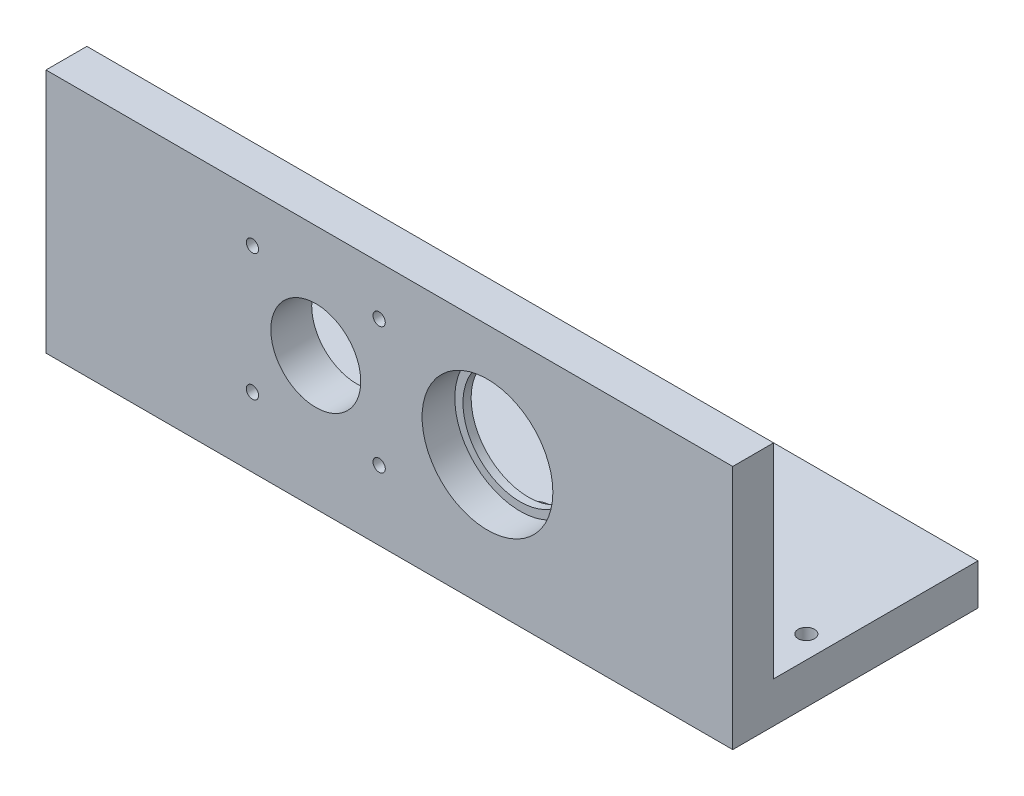
from build123d import *

# Parameters (mm, degrees)
SKIZZE1_W                       = 168
SKIZZE1_H                       = 60
AUFSATZ_LINEAR_AUSTRAGEN1_DEPTH = 10
SKIZZE2_R                       = 14
SCHNITT_LINEAR_AUSTRAGEN1_DEPTH = 27
SKIZZE3_R                       = 16
SCHNITT_LINEAR_AUSTRAGEN2_DEPTH = 8
SKIZZE4_R                       = 11
SCHNITT_LINEAR_AUSTRAGEN3_DEPTH = 21.6
SKIZZE5_W                       = 168
SKIZZE5_H                       = 10
AUFSATZ_LINEAR_AUSTRAGEN2_DEPTH = 50
SKIZZE6_R                       = 2
SCHNITT_LINEAR_AUSTRAGEN4_DEPTH = 10
SKIZZE7_R                       = 2.5
SCHNITT_LINEAR_AUSTRAGEN5_DEPTH = 10
SKIZZE8_R                       = 1.5
SCHNITT_LINEAR_AUSTRAGEN6_DEPTH = 27
FASE1_SIZE                      = 2
FASE2_SIZE                      = 2
FASE3_SIZE                      = 2
FASE4_SIZE                      = 2


with BuildPart() as part:
    # Skizze1 → Aufsatz-Linear austragen1 (new body)
    with BuildSketch(Plane.XY):
        with Locations((84, 30)):
            Rectangle(SKIZZE1_W, SKIZZE1_H)
    extrude(amount=AUFSATZ_LINEAR_AUSTRAGEN1_DEPTH)

    # Skizze2 → Schnitt-Linear austragen1 (cut)
    with BuildSketch(Plane.XY.offset(10)):
        with Locations((108, 32.5)):
            Circle(SKIZZE2_R)
    extrude(amount=-SCHNITT_LINEAR_AUSTRAGEN1_DEPTH, mode=Mode.SUBTRACT)

    # Skizze3 → Schnitt-Linear austragen2 (cut)
    with BuildSketch(Plane.XY.offset(10)):
        with Locations((108, 32.5)):
            Circle(SKIZZE3_R)
    extrude(amount=-SCHNITT_LINEAR_AUSTRAGEN2_DEPTH, mode=Mode.SUBTRACT)

    # Skizze4 → Schnitt-Linear austragen3 (cut)
    with BuildSketch(Plane(origin=(0, 0, 0), x_dir=(-1, 0, 0), z_dir=(0, 0, -1))):
        with Locations((-66, 32.50089026)):
            Circle(SKIZZE4_R)
    extrude(amount=-SCHNITT_LINEAR_AUSTRAGEN3_DEPTH, mode=Mode.SUBTRACT)

    # Skizze5 → Aufsatz-Linear austragen2 (add)
    with BuildSketch(Plane(origin=(0, 0, 0), x_dir=(-1, 0, 0), z_dir=(0, 0, -1))):
        with Locations((-84, 5)):
            Rectangle(SKIZZE5_W, SKIZZE5_H)
    extrude(amount=AUFSATZ_LINEAR_AUSTRAGEN2_DEPTH)

    # Skizze6 → Schnitt-Linear austragen4 (cut)
    with BuildSketch(Plane(origin=(0, 10, 0), x_dir=(1, 0, 0), z_dir=(0, 1, 0))):
        with Locations((5.5, 13.5)):
            Circle(SKIZZE6_R)
        with Locations((31.5, 13.5)):
            Circle(SKIZZE6_R)
        with Locations((162.5, 13.5)):
            Circle(SKIZZE6_R)
        with Locations((136.5, 13.5)):
            Circle(SKIZZE6_R)
    extrude(amount=-SCHNITT_LINEAR_AUSTRAGEN4_DEPTH, mode=Mode.SUBTRACT)

    # Skizze7 → Schnitt-Linear austragen5 (cut)
    with BuildSketch(Plane(origin=(0, 10, 0), x_dir=(1, 0, 0), z_dir=(0, 1, 0))):
        with Locations((104, 20)):
            Circle(SKIZZE7_R)
        with Locations((64, 20)):
            Circle(SKIZZE7_R)
        with Locations((64, 5)):
            Circle(SKIZZE7_R)
        with Locations((104, 5)):
            Circle(SKIZZE7_R)
    extrude(amount=-SCHNITT_LINEAR_AUSTRAGEN5_DEPTH, mode=Mode.SUBTRACT)

    # Skizze8 → Schnitt-Linear austragen6 (cut)
    with BuildSketch(Plane(origin=(0, 0, 0), x_dir=(-1, 0, 0), z_dir=(0, 0, -1))):
        with Locations((-50.5, 48)):
            Circle(SKIZZE8_R)
        with Locations((-50.5, 17)):
            Circle(SKIZZE8_R)
        with Locations((-81.5, 17)):
            Circle(SKIZZE8_R)
        with Locations((-81.5, 48)):
            Circle(SKIZZE8_R)
    extrude(amount=-SCHNITT_LINEAR_AUSTRAGEN6_DEPTH, mode=Mode.SUBTRACT)

    # Fase1
    fase1_edges = [part.edges().sort_by_distance(p)[0] for p in [
        (61.5, 10, -5),
    ]]
    chamfer(fase1_edges, length=FASE1_SIZE)

    # Fase2
    fase2_edges = [part.edges().sort_by_distance(p)[0] for p in [
        (61.5, 10, -20),
    ]]
    chamfer(fase2_edges, length=FASE2_SIZE)

    # Fase3
    fase3_edges = [part.edges().sort_by_distance(p)[0] for p in [
        (101.5, 10, -20),
    ]]
    chamfer(fase3_edges, length=FASE3_SIZE)

    # Fase4
    fase4_edges = [part.edges().sort_by_distance(p)[0] for p in [
        (101.5, 10, -5),
    ]]
    chamfer(fase4_edges, length=FASE4_SIZE)


solid = part.part
